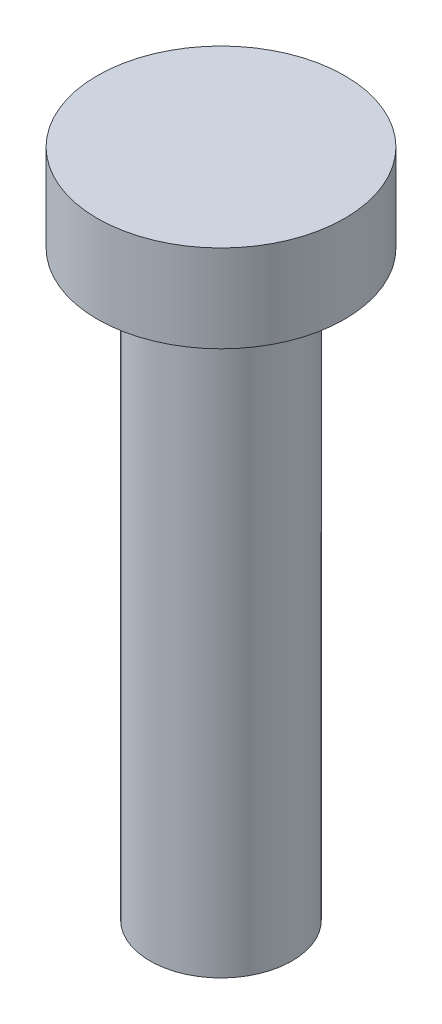
from build123d import *

# Parameters (mm, degrees)
SKETCH1_R           = 4.25
BOSS_EXTRUDE1_DEPTH = 3
SKETCH2_R           = 2.44
BOSS_EXTRUDE2_DEPTH = 20


with BuildPart() as part:
    # Sketch1 → Boss-Extrude1 (new body)
    with BuildSketch(Plane(origin=(0, 0, 0), x_dir=(1, 0, 0), z_dir=(0, 1, 0))):
        Circle(SKETCH1_R)
    extrude(amount=BOSS_EXTRUDE1_DEPTH)

    # Sketch2 → Boss-Extrude2 (add)
    with BuildSketch(Plane.XZ):
        Circle(SKETCH2_R)
    extrude(amount=BOSS_EXTRUDE2_DEPTH)


solid = part.part
